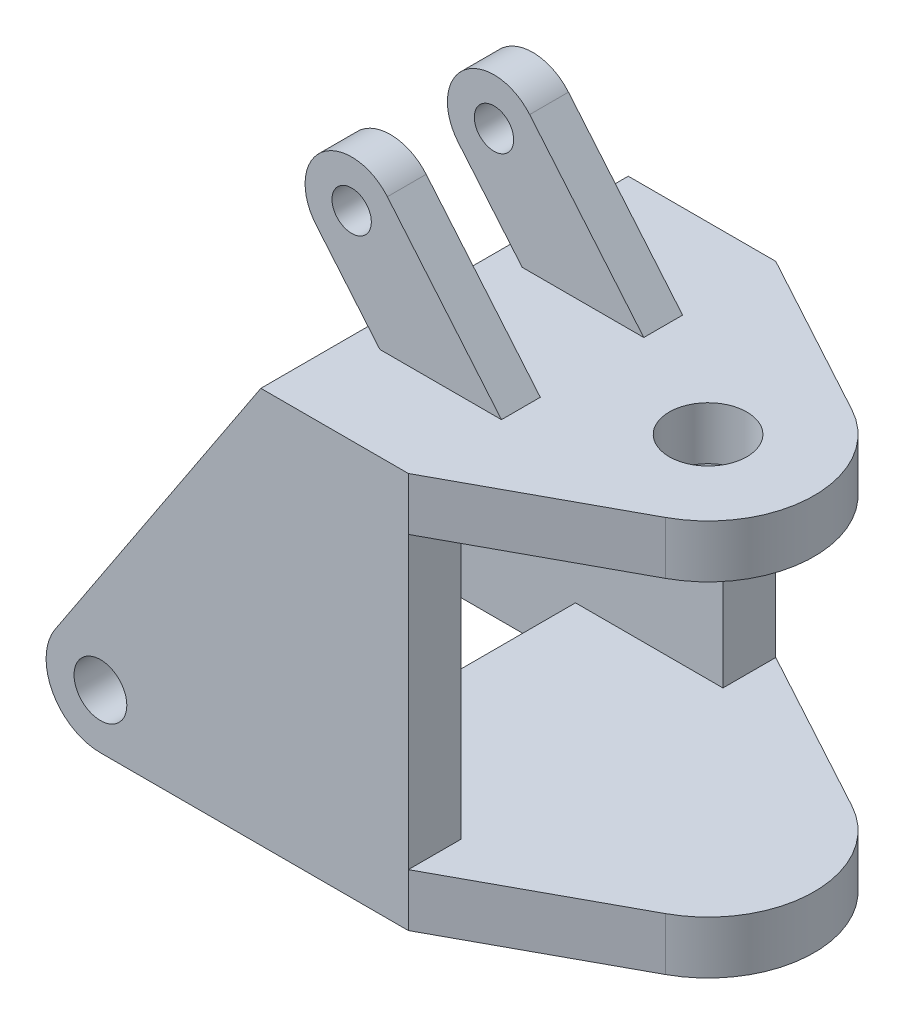
from build123d import *

# Parameters (mm, degrees)
SKETCH2_R           = 51
BOSS_EXTRUDE1_DEPTH = 102
SKETCH3_R           = 75
BOSS_EXTRUDE2_DEPTH = 102
BOSS_EXTRUDE3_DEPTH = 102
BOSS_EXTRUDE7_START = 100
SKETCH17_R          = 38
BOSS_EXTRUDE7_DEPTH = 75


with BuildPart() as part:
    # Sketch2 → Boss-Extrude1 (new body)
    with BuildSketch(Plane.XY.offset(355)):
        with BuildLine():
            Line((-285, 765), (0, 765))
            Line((0, 765), (0, 0))
            Line((0, 0), (-595, 0))
            ThreePointArc((-595, 0), (-687.466864274, 55.251844141), (-682.620113823, 162.859447402))
            Line((-682.620113823, 162.859447402), (-285, 765))
        make_face()
        with Locations((-595, 105)):
            Circle(SKETCH2_R, mode=Mode.SUBTRACT)
    boss_extrude1 = extrude(amount=BOSS_EXTRUDE1_DEPTH)

    # Sketch3 → Boss-Extrude2 (add)
    with BuildSketch(Plane(origin=(0, 765, 0), x_dir=(1, 0, 0), z_dir=(0, 1, 0))):
        with BuildLine():
            Line((0, -457), (-285, -457))
            Line((-285, -457), (-285, 253))
            Line((-285, 253), (0, 253))
            Line((0, 253), (322.019203343, 78.15740693))
            ThreePointArc((322.019203343, 78.15740693), (429.201471167, -102), (322.019203343, -282.15740693))
            Line((322.019203343, -282.15740693), (0, -457))
        make_face()
        with Locations((224.201471167, -102)):
            Circle(SKETCH3_R, mode=Mode.SUBTRACT)
    extrude(amount=-BOSS_EXTRUDE2_DEPTH)

    # Mirror2: Boss-Extrude1 across plane
    add(boss_extrude1.mirror(Plane.XY.offset(102)))

    # Sketch9 → Boss-Extrude3 (add)
    with BuildSketch(Plane.XZ):
        with BuildLine():
            Line((0, -151), (0, -253))
            Line((0, -253), (322.019203343, -78.15740693))
            ThreePointArc((322.019203343, -78.15740693), (429.201471167, 102), (322.019203343, 282.15740693))
            Line((322.019203343, 282.15740693), (0, 457))
            Line((0, 457), (0, 355))
            Line((0, 355), (-285, 355))
            Line((-285, 355), (-285, -151))
            Line((-285, -151), (0, -151))
        make_face()
    extrude(amount=-BOSS_EXTRUDE3_DEPTH)

    # Sketch17 → Boss-Extrude7 (add)
    with BuildSketch(Plane.XY.offset(102).offset(BOSS_EXTRUDE7_START)):
        with BuildLine():
            Line((-234.97331208, 765), (0, 765))
            Line((0, 765), (-220.558080551, 1027.850884872))
            ThreePointArc((-220.558080551, 1027.850884872), (-347.352965303, 1038.943999881), (-358.446080312, 912.149115128))
            Line((-358.446080312, 912.149115128), (-234.97331208, 765))
        make_face()
        with Locations((-289.502080431, 970)):
            Circle(SKETCH17_R, mode=Mode.SUBTRACT)
    boss_extrude7 = extrude(amount=BOSS_EXTRUDE7_DEPTH)

    # Mirror5: Boss-Extrude7 across plane
    add(boss_extrude7.mirror(Plane.XY.offset(102)))


solid = part.part
